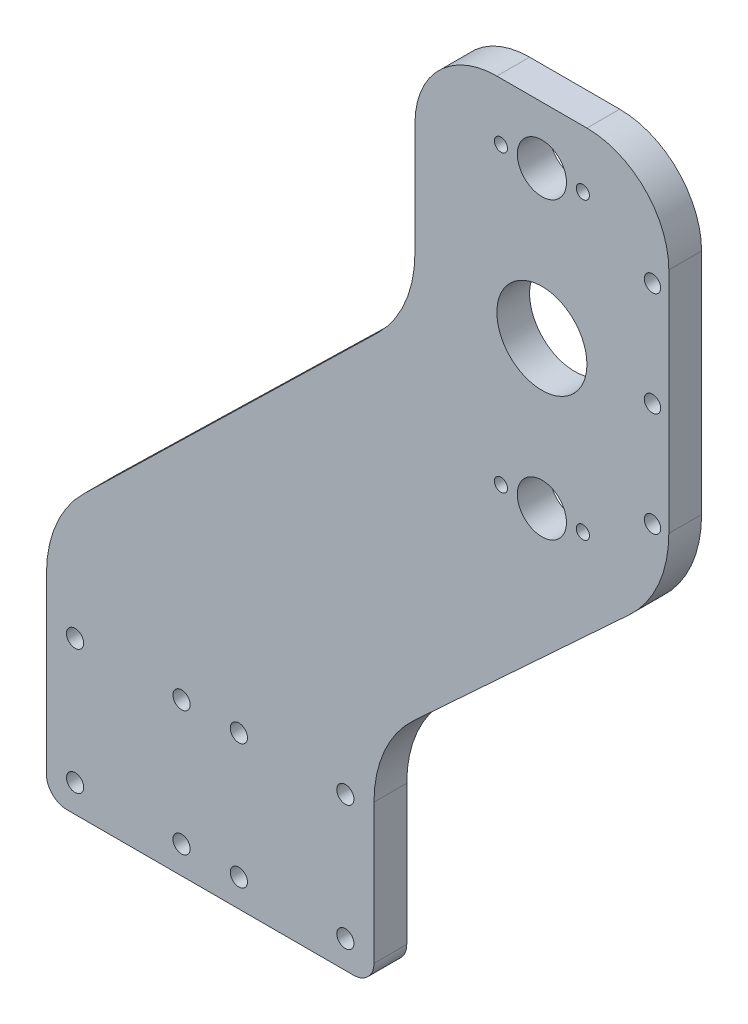
from build123d import *

# Parameters (mm, degrees)
SKETCH1_R           = 2.1
SKETCH1_R_2         = 6
SKETCH1_R_3         = 11
SKETCH1_R_4         = 2
SKETCH1_R_5         = 1.6
BOSS_EXTRUDE1_DEPTH = 8


with BuildPart() as part:
    # Sketch1 → Boss-Extrude1 (new body)
    with BuildSketch(Plane.XY):
        with BuildLine():
            Line((-58.634566509, -94.315974521), (11.365433491, -94.315974521))
            ThreePointArc((11.365433491, -94.315974521), (14.900967397, -92.851508427), (16.365433491, -89.315974521))
            Line((16.365433491, -89.315974521), (16.365433491, -55.206132823))
            ThreePointArc((16.365433491, -55.206132823), (18.877822606, -43.188177597), (25.994183345, -33.18314103))
            Line((25.994183345, -33.18314103), (78.736683637, 15.603630397))
            ThreePointArc((78.736683637, 15.603630397), (85.853044376, 25.608666964), (88.365433491, 37.62662219))
            Line((88.365433491, 37.62662219), (88.365433491, 93.348359509))
            ThreePointArc((88.365433491, 93.348359509), (82.507569115, 107.490495133), (68.365433491, 113.348359509))
            Line((68.365433491, 113.348359509), (46.365433491, 113.348359509))
            ThreePointArc((46.365433491, 113.348359509), (32.223297867, 107.490495133), (26.365433491, 93.348359509))
            Line((26.365433491, 93.348359509), (26.365433491, 66.006418518))
            ThreePointArc((26.365433491, 66.006418518), (24.005761373, 54.343988473), (17.29794852, 44.516192494))
            Line((17.29794852, 44.516192494), (-54.567081538, -25.483807506))
            ThreePointArc((-54.567081538, -25.483807506), (-61.274894391, -35.311603484), (-63.634566509, -46.97403353))
            Line((-63.634566509, -46.97403353), (-63.634566509, -89.315974521))
            ThreePointArc((-63.634566509, -89.315974521), (-62.170100415, -92.851508427), (-58.634566509, -94.315974521))
        make_face()
        with Locations((-56.634566509, -57.065974521)):
            Circle(SKETCH1_R, mode=Mode.SUBTRACT)
        with Locations((-30.634566509, -57.065974521)):
            Circle(SKETCH1_R, mode=Mode.SUBTRACT)
        with Locations((-30.634566509, -87.565974521)):
            Circle(SKETCH1_R, mode=Mode.SUBTRACT)
        with Locations((-56.634566509, -87.565974521)):
            Circle(SKETCH1_R, mode=Mode.SUBTRACT)
        with Locations((9.365433491, -87.565974521)):
            Circle(SKETCH1_R, mode=Mode.SUBTRACT)
        with Locations((-16.634566509, -87.565974521)):
            Circle(SKETCH1_R, mode=Mode.SUBTRACT)
        with Locations((-16.634566509, -57.065974521)):
            Circle(SKETCH1_R, mode=Mode.SUBTRACT)
        with Locations((9.365433491, -57.065974521)):
            Circle(SKETCH1_R, mode=Mode.SUBTRACT)
        with Locations((57.365433491, 99.348359509)):
            Circle(SKETCH1_R_2, mode=Mode.SUBTRACT)
        with Locations((57.365433491, 27.408359509)):
            Circle(SKETCH1_R_2, mode=Mode.SUBTRACT)
        with Locations((57.365433491, 63.378359509)):
            Circle(SKETCH1_R_3, mode=Mode.SUBTRACT)
        with Locations((84.365433491, 37.62662219)):
            Circle(SKETCH1_R_4, mode=Mode.SUBTRACT)
        with Locations((84.375885899, 88.528341433)):
            Circle(SKETCH1_R_4, mode=Mode.SUBTRACT)
        with Locations((47.365433491, 99.348359509)):
            Circle(SKETCH1_R_5, mode=Mode.SUBTRACT)
        with Locations((47.365433491, 27.408359509)):
            Circle(SKETCH1_R_5, mode=Mode.SUBTRACT)
        with Locations((67.365433491, 99.348359509)):
            Circle(SKETCH1_R_5, mode=Mode.SUBTRACT)
        with Locations((67.365433491, 27.408359509)):
            Circle(SKETCH1_R_5, mode=Mode.SUBTRACT)
        with Locations((84.370659695, 63.077481811)):
            Circle(SKETCH1_R_4, mode=Mode.SUBTRACT)
    extrude(amount=BOSS_EXTRUDE1_DEPTH)


solid = part.part
